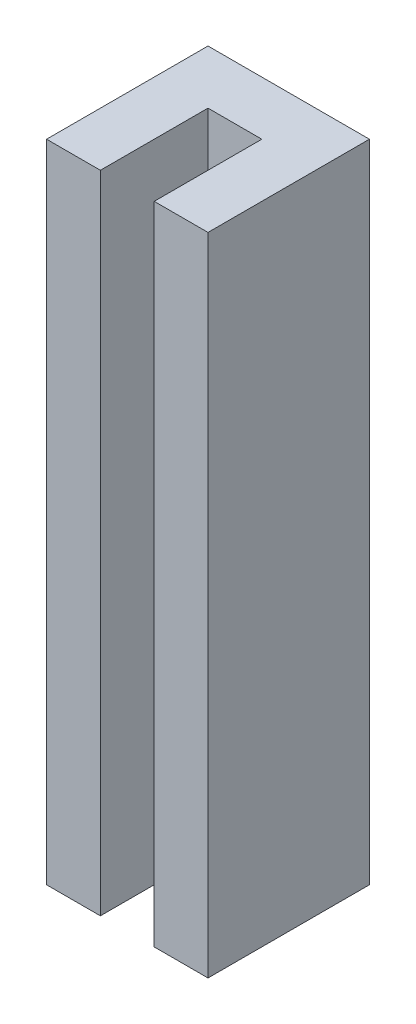
from build123d import *

# Parameters (mm, degrees)
EXTRUDE1_DEPTH                  = 19.05
F_4_40_TAPPED_HOLE1_D           = 2.2606
F_4_40_TAPPED_HOLE1_DEPTH       = 8.89
F_4_40_TAPPED_HOLE1_CBORE_D     = 2.8448
F_4_40_TAPPED_HOLE1_CBORE_DEPTH = 5.588
F_4_40_TAPPED_HOLE1_TIP         = 0.679152758


with BuildPart() as part:
    # Sketch1 → Extrude1 (new body, symmetric)
    with BuildSketch(Plane(origin=(0, 0, 0), x_dir=(1, 0, 0), z_dir=(0, 1, 0))):
        Polygon((-4.7625, -4.7625), (-1.5875, -4.7625), (-1.5875, 1.5875), (1.5875, 1.5875), (1.5875, -4.7625), (4.7625, -4.7625), (4.7625, 4.7625), (-4.7625, 4.7625), align=None)
    extrude(amount=EXTRUDE1_DEPTH, both=True)

    # #4-40 Tapped Hole1
    with Locations(Plane(origin=(0, 7.9375, -4.7625), x_dir=(-1, 0, 0), z_dir=(0, 0, -1))):
        with Locations((0, 0), (0, -22.225)):
            CounterBoreHole(F_4_40_TAPPED_HOLE1_D / 2, F_4_40_TAPPED_HOLE1_CBORE_D / 2, F_4_40_TAPPED_HOLE1_CBORE_DEPTH, depth=F_4_40_TAPPED_HOLE1_DEPTH)
            with Locations((0, 0, -(F_4_40_TAPPED_HOLE1_DEPTH + F_4_40_TAPPED_HOLE1_TIP / 2))):  # 118° drill point
                Cone(0, F_4_40_TAPPED_HOLE1_D / 2, F_4_40_TAPPED_HOLE1_TIP, mode=Mode.SUBTRACT)


solid = part.part
